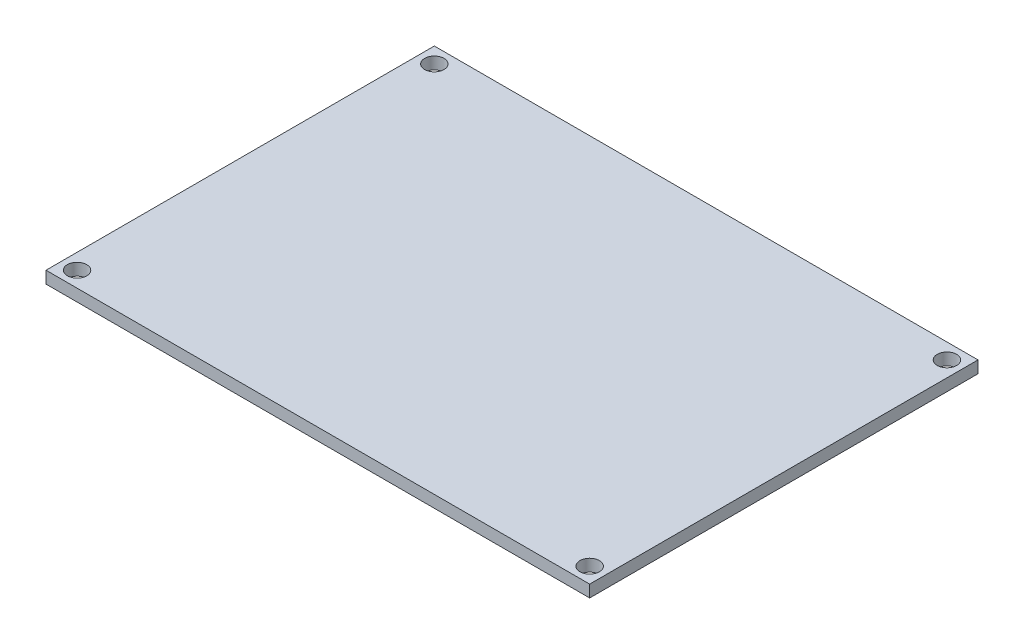
from build123d import *

# Parameters (mm, degrees)
SKETCH1_W           = 70
SKETCH1_H           = 50
BOSS_EXTRUDE1_DEPTH = 1.55
SKETCH2_R           = 1.25
CUT_EXTRUDE1_DEPTH  = 2.55


with BuildPart() as part:
    # Sketch1 → Boss-Extrude1 (new body)
    with BuildSketch(Plane(origin=(0, 0, 0), x_dir=(1, 0, 0), z_dir=(0, 1, 0))):
        with Locations((35, 25)):
            Rectangle(SKETCH1_W, SKETCH1_H)
    extrude(amount=BOSS_EXTRUDE1_DEPTH)

    # Sketch2 → Cut-Extrude1 (cut, through all)
    with BuildSketch(Plane(origin=(0, 1.55, 0), x_dir=(1, 0, 0), z_dir=(0, 1, 0))):
        with Locations((2, 48)):
            Circle(SKETCH2_R)
        with Locations((68, 48)):
            Circle(SKETCH2_R)
        with Locations((68, 2)):
            Circle(SKETCH2_R)
        with Locations((2, 2)):
            Circle(SKETCH2_R)
    extrude(amount=-CUT_EXTRUDE1_DEPTH, mode=Mode.SUBTRACT)


solid = part.part
